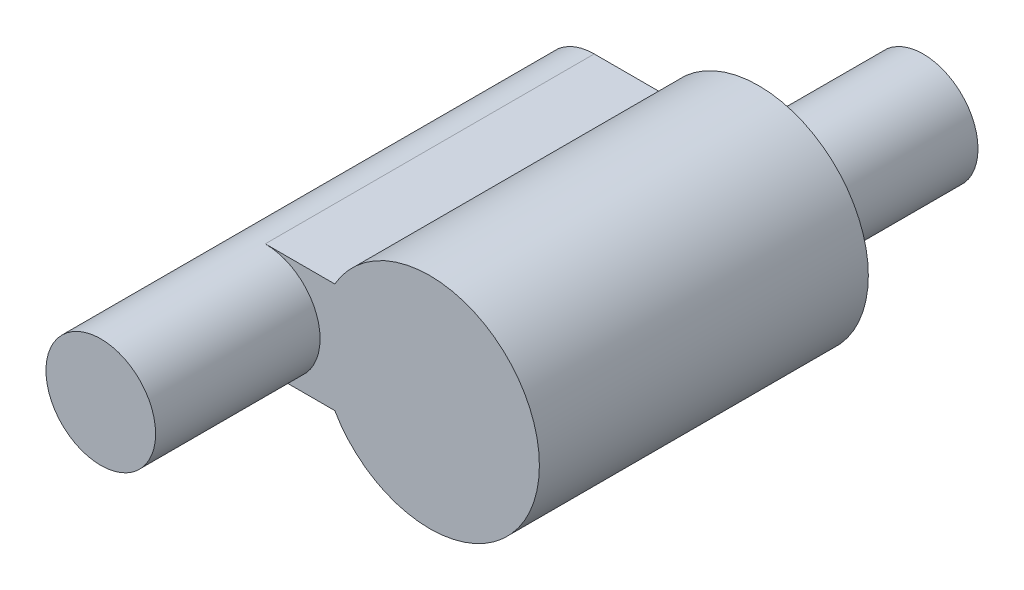
from build123d import *

# Parameters (mm, degrees)
BOSS_EXTRUDE1_DEPTH = 6
SKETCH2_R           = 1
BOSS_EXTRUDE2_DEPTH = 3
SKETCH3_R           = 1
BOSS_EXTRUDE3_DEPTH = 3


with BuildPart() as part:
    # Sketch1 → Boss-Extrude1 (new body)
    with BuildSketch(Plane.XY):
        with BuildLine():
            Line((-7.068000803, 8.031631057), (-5.800051611, 8.031631057))
            ThreePointArc((-5.800051611, 8.031631057), (-2.068000803, 7.031631057), (-5.800051611, 6.031631057))
            Line((-5.800051611, 6.031631057), (-7.068000803, 6.031631057))
            ThreePointArc((-7.068000803, 6.031631057), (-8.068000803, 7.031631057), (-7.068000803, 8.031631057))
        make_face()
    extrude(amount=BOSS_EXTRUDE1_DEPTH)

    # Sketch2 → Boss-Extrude2 (add)
    with BuildSketch(Plane.XY.offset(6)):
        with Locations((-7.068000803, 7.031631057)):
            Circle(SKETCH2_R)
    extrude(amount=BOSS_EXTRUDE2_DEPTH)

    # Sketch3 → Boss-Extrude3 (add)
    with BuildSketch(Plane(origin=(0, 0, 0), x_dir=(-1, 0, 0), z_dir=(0, 0, -1))):
        with Locations((4.068000803, 7.031631057)):
            Circle(SKETCH3_R)
    extrude(amount=BOSS_EXTRUDE3_DEPTH)


solid = part.part
